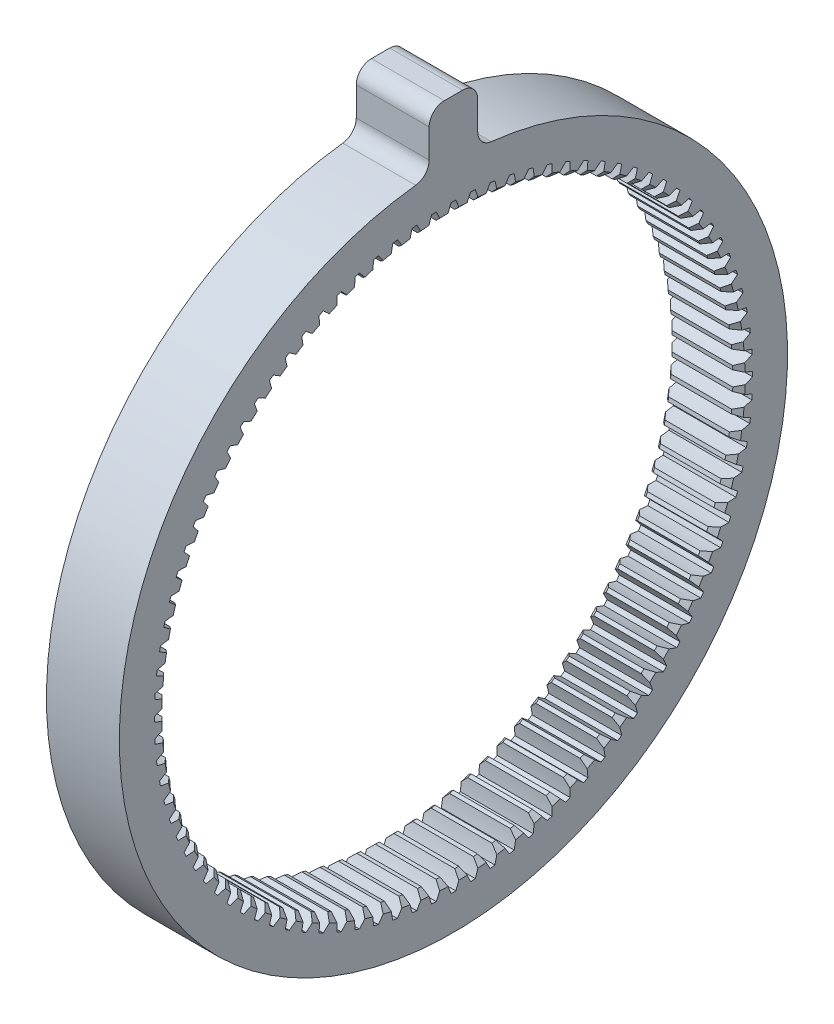
from build123d import *

# Parameters (mm, degrees)
BASPROSKE_W         = 12
BASPROSKE_H         = 8
CHAMFER1_SIZE       = 1
TOOTHCUT_DEPTH      = 13
TEETHCUTS_COUNT     = 96
SKETCH1_W           = 8
SKETCH1_H           = 12
BOSS_EXTRUDE1_DEPTH = 12
FILLET1_R           = 2.5


with BuildPart() as part:
    # BasProSke → Base-Revolve (revolve)
    with BuildSketch(Plane(origin=(0, 0, 0), x_dir=(1, 0, 0), z_dir=(0, 1, 0))):
        with Locations((6, 51)):
            Rectangle(BASPROSKE_W, BASPROSKE_H)
    revolve(axis=Axis((-10, 0, 0), (1, 0, 0)))

    # Chamfer1
    chamfer1_edges = [part.edges().sort_by_distance(p)[0] for p in [
        (0, 0, 47),
        (12, 0, 47),
    ]]
    chamfer(chamfer1_edges, length=CHAMFER1_SIZE)

    # TooCutSke → ToothCut (cut, through all)
    with BuildSketch(Plane(origin=(0, 0, 0), x_dir=(0, 0, -1), z_dir=(1, 0, 0))):
        with BuildLine():
            ThreePointArc((1.223891253, 46.958653466), (0.836069243, 48.114648891), (0.390036542, 49.249455555))
            ThreePointArc((0.390036542, 49.249455555), (0, 49.251), (-0.390036542, 49.249455555))
            ThreePointArc((-0.390036542, 49.249455555), (-0.836069243, 48.114648891), (-1.223891253, 46.958653466))
            ThreePointArc((-1.223891253, 46.958653466), (0, 46.9746), (1.223891253, 46.958653466))
        make_face()
    toothcut = extrude(amount=TOOTHCUT_DEPTH, mode=Mode.SUBTRACT)

    # TeethCuts: ToothCut ×96 about axis
    teethcuts_axis = Axis((0, 0, 0), (1, 0, 0))
    for i in range(1, TEETHCUTS_COUNT):
        add(toothcut.rotate(teethcuts_axis, i * 360 / TEETHCUTS_COUNT), mode=Mode.SUBTRACT)

    # Sketch1 → Boss-Extrude1 (add)
    with BuildSketch(Plane(origin=(12, 0, 0), x_dir=(0, 0, -1), z_dir=(1, 0, 0))):
        with Locations((0, 58.347397261)):
            Rectangle(SKETCH1_W, SKETCH1_H)
    extrude(amount=-BOSS_EXTRUDE1_DEPTH)

    # Fillet1
    fillet1_edges = [part.edges().sort_by_distance(p)[0] for p in [
        (6, 54.854352608, -4),
        (6, 54.854352608, 4),
        (6, 64.347397261, -4),
        (6, 64.347397261, 4),
    ]]
    fillet(fillet1_edges, radius=FILLET1_R)


solid = part.part
